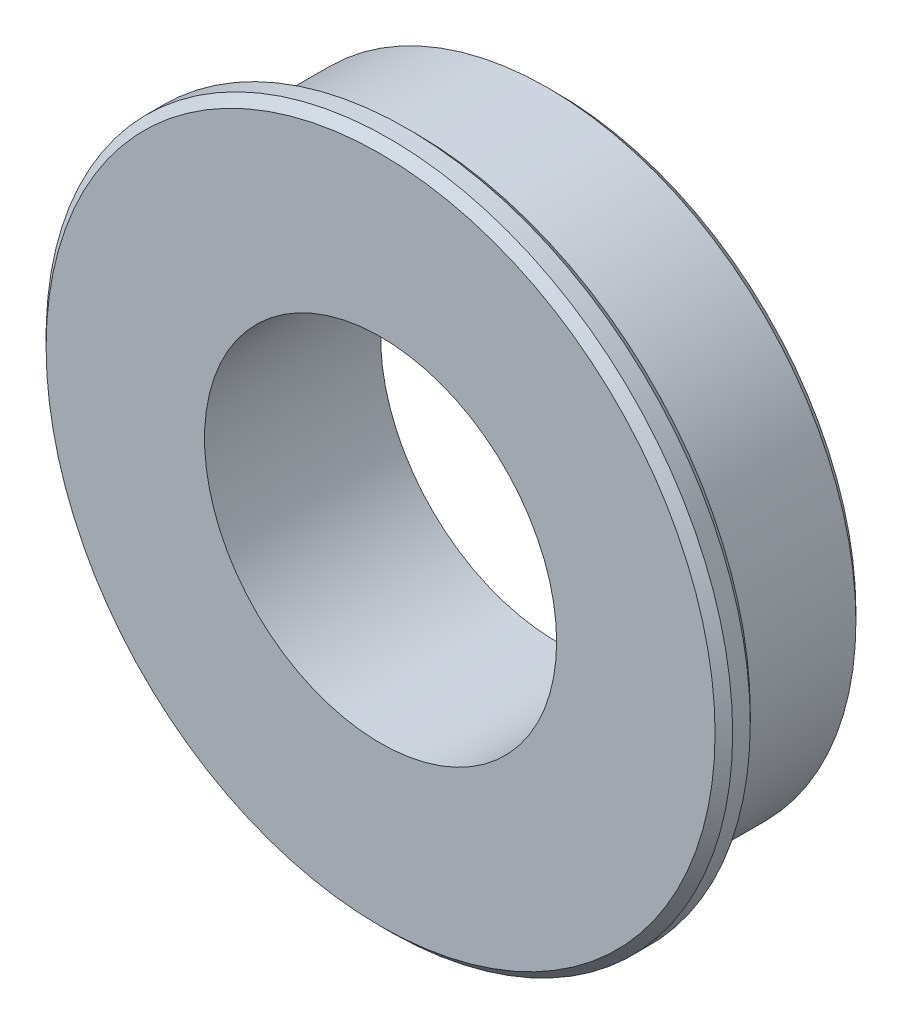
from build123d import *

# Parameters (mm, degrees)
SKETCH_1_R      = 7
SKETCH_1_R_2    = 4
EXTRUDE_1_DEPTH = 2
SKETCH_2_R      = 7.8
SKETCH_2_R_2    = 4
EXTRUDE_2_DEPTH = 0.8
CHAMFER_1_SIZE  = 0.2


with BuildPart() as part:
    # 草图1 → 凸台-拉伸1 (new body, symmetric)
    with BuildSketch(Plane.XY):
        Circle(SKETCH_1_R)
        Circle(SKETCH_1_R_2, mode=Mode.SUBTRACT)
    extrude(amount=EXTRUDE_1_DEPTH, both=True)

    # 草图2 → 凸台-拉伸2 (add)
    with BuildSketch(Plane.XY.offset(2)):
        Circle(SKETCH_2_R)
        Circle(SKETCH_2_R_2, mode=Mode.SUBTRACT)
    extrude(amount=-EXTRUDE_2_DEPTH)

    # 倒角1
    chamfer_1_edges = [part.edges().sort_by_distance(p)[0] for p in [
        (-7.8, 0, 2),
        (-7.8, 0, 1.2),
        (-7, 0, -2),
    ]]
    chamfer(chamfer_1_edges, length=CHAMFER_1_SIZE)


solid = part.part
